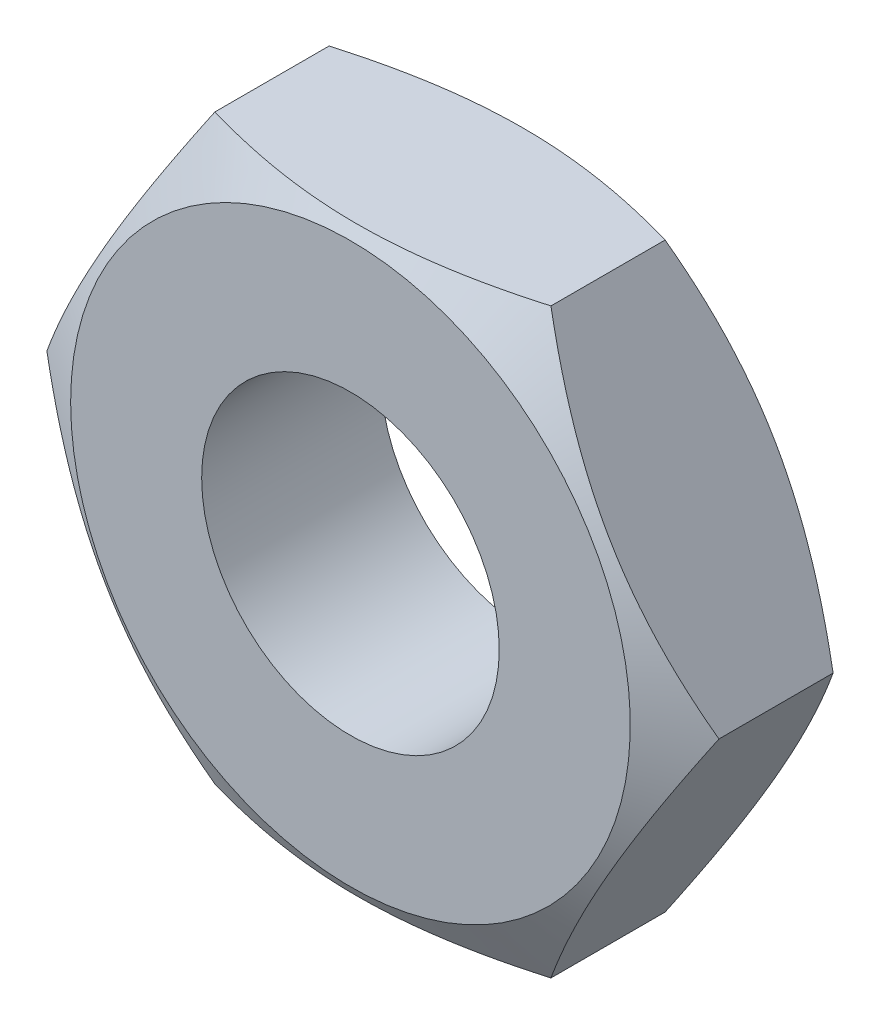
from build123d import *

# Parameters (mm, degrees)
BASE_EXTRUSION_DEPTH    = 4
ESQUISSE2_R             = 3.3234375
ENL_V_MAT_EXTRU_1_DEPTH = 5


with BuildPart() as part:
    # Esquisse1 → Base-Extrusion (new body)
    with BuildSketch(Plane.XY):
        Polygon((-7.505553499, 0), (-3.75277675, 6.5), (3.75277675, 6.5), (7.505553499, 0), (3.75277675, -6.5), (-3.75277675, -6.5), align=None)
    extrude(amount=BASE_EXTRUSION_DEPTH)

    # Esquisse2 → Enlèv. mat.-Extru.1 (cut, through all)
    with BuildSketch(Plane.XY.offset(4)):
        Circle(ESQUISSE2_R)
    extrude(amount=-ENL_V_MAT_EXTRU_1_DEPTH, mode=Mode.SUBTRACT)

    # Esquisse3 → Enlever de la matière-Révolution1 (revolve, cut)
    with BuildSketch(Plane(origin=(0, 0, 0), x_dir=(1, 0, 0), z_dir=(0, 1, 0))):
        Polygon((-6.25, 0), (-7.505553499, 0), (-7.505553499, -0.724894151), align=None)
    enlever_de_la_mati_re_r_volution1 = revolve(axis=Axis((0, 0, 0), (0, 0, 1)), mode=Mode.SUBTRACT)

    # Symétrie1: Enlever de la matière-Révolution1 across Plan4
    add(enlever_de_la_mati_re_r_volution1.mirror(Plane(origin=(0, 0, 2), x_dir=(-1, 0, 0), z_dir=(0, 0, -1))), mode=Mode.SUBTRACT)


solid = part.part
